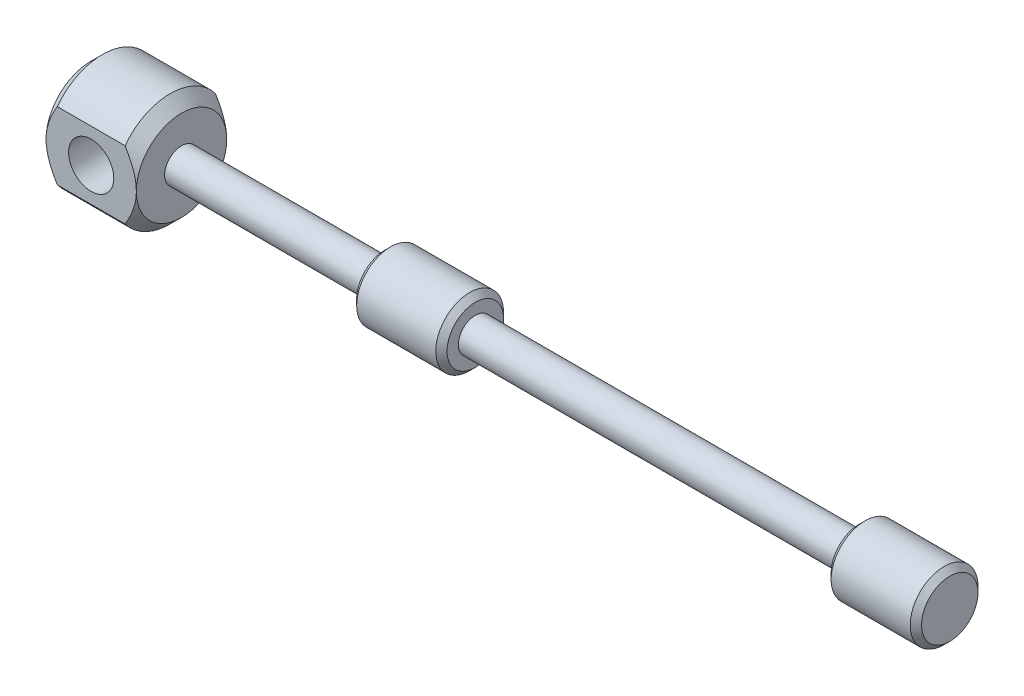
from build123d import *

# Parameters (mm, degrees)
SKETCH1_R               = 1.5
BOSS_EXTRUDE1_DEPTH     = 50
SKETCH2_R               = 3
BOSS_EXTRUDE2_DEPTH     = 8
CHAMFER1_SIZE           = 0.5
SKETCH3_R               = 3
BOSS_EXTRUDE4_DEPTH     = 8
CHAMFER2_SIZE           = 0.5
SKETCH5_R               = 1.5
BOSS_EXTRUDE5_DEPTH     = 26
SKETCH6_R               = 5
BOSS_EXTRUDE6_DEPTH     = 8
SKETCH7_R               = 2
CUT_EXTRUDE1_DEPTH      = 6
CUT_EXTRUDE1_DEPTH_BACK = 6
CHAMFER3_SIZE           = 1
CUT_EXTRUDE2_DEPTH      = 1
CUT_EXTRUDE2_DEPTH_BACK = 77


with BuildPart() as part:
    # Sketch1 → Boss-Extrude1 (new body)
    with BuildSketch(Plane(origin=(0, 0, 0), x_dir=(0, 0, -1), z_dir=(1, 0, 0))):
        Circle(SKETCH1_R)
    extrude(amount=BOSS_EXTRUDE1_DEPTH)

    # Sketch2 → Boss-Extrude2 (add)
    with BuildSketch(Plane(origin=(50, 0, 0), x_dir=(0, 0, -1), z_dir=(1, 0, 0))):
        Circle(SKETCH2_R)
    extrude(amount=-BOSS_EXTRUDE2_DEPTH)

    # Chamfer1
    chamfer1_edges = [part.edges().sort_by_distance(p)[0] for p in [
        (42, 0, 3),
        (50, 0, 3),
    ]]
    chamfer(chamfer1_edges, length=CHAMFER1_SIZE)

    # Sketch3 → Boss-Extrude4 (add)
    with BuildSketch(Plane.ZY):
        Circle(SKETCH3_R)
    extrude(amount=-BOSS_EXTRUDE4_DEPTH)

    # Chamfer2
    chamfer2_edges = [part.edges().sort_by_distance(p)[0] for p in [
        (8, 0, -3),
        (0, 0, -3),
    ]]
    chamfer(chamfer2_edges, length=CHAMFER2_SIZE)

    # Sketch5 → Boss-Extrude5 (add)
    with BuildSketch(Plane.ZY):
        Circle(SKETCH5_R)
    extrude(amount=BOSS_EXTRUDE5_DEPTH)

    # Sketch6 → Boss-Extrude6 (add)
    with BuildSketch(Plane.ZY.offset(26)):
        Circle(SKETCH6_R)
    extrude(amount=-BOSS_EXTRUDE6_DEPTH)

    # Sketch7 → Cut-Extrude1 (cut, two sides)
    with BuildSketch(Plane.XY) as cut_extrude1_sk:
        with Locations((-22, 0)):
            Circle(SKETCH7_R)
    extrude(amount=CUT_EXTRUDE1_DEPTH, mode=Mode.SUBTRACT)
    extrude(cut_extrude1_sk.sketch, amount=-CUT_EXTRUDE1_DEPTH_BACK, mode=Mode.SUBTRACT)

    # Chamfer3
    chamfer3_edges = [part.edges().sort_by_distance(p)[0] for p in [
        (-18, 0, -5),
        (-26, 0, -5),
    ]]
    chamfer(chamfer3_edges, length=CHAMFER3_SIZE)

    # Sketch8 → Cut-Extrude2 (cut, two sides)
    with BuildSketch(Plane.ZY.offset(26)) as cut_extrude2_sk:
        with BuildLine():
            Line((-4, 4), (-4, -4))
            ThreePointArc((-4, -4), (-5.656854249, 0), (-4, 4))
        make_face()
        with BuildLine():
            Line((4, 4), (4, -4))
            ThreePointArc((4, -4), (5.656854249, 0), (4, 4))
        make_face()
    extrude(amount=CUT_EXTRUDE2_DEPTH, mode=Mode.SUBTRACT)
    extrude(cut_extrude2_sk.sketch, amount=-CUT_EXTRUDE2_DEPTH_BACK, mode=Mode.SUBTRACT)


solid = part.part
